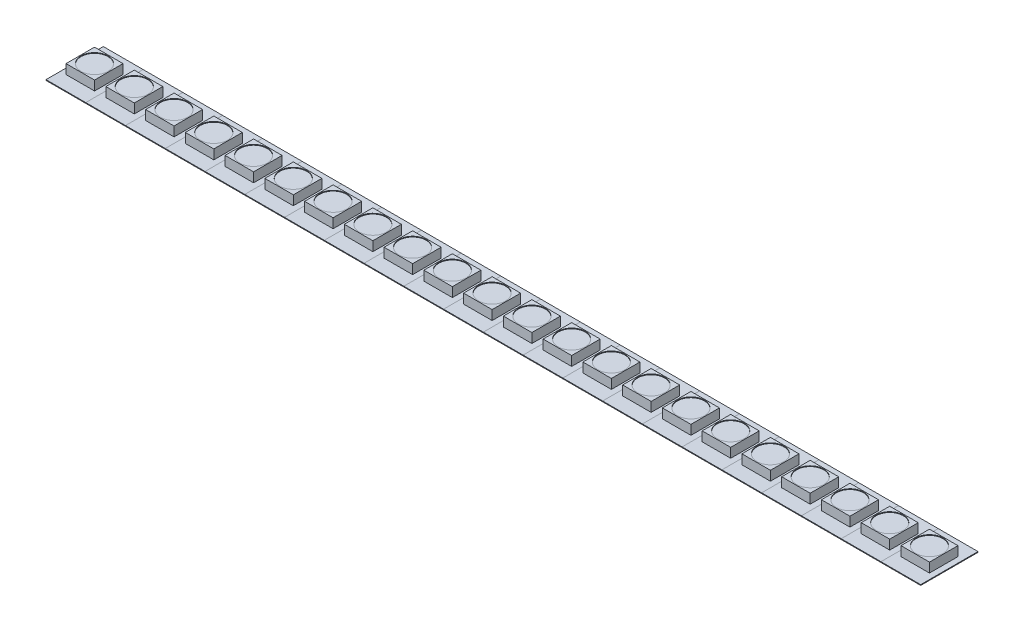
from build123d import *

# Parameters (mm, degrees)
SKETCH1_W           = 6.9088
SKETCH1_H           = 9.9568
BOSS_EXTRUDE1_DEPTH = 0.127
SKETCH3_W           = 4.953
SKETCH3_H           = 4.953
BOSS_EXTRUDE3_DEPTH = 1.651
SKETCH5_R           = 2.348345572
CUT_EXTRUDE1_DEPTH  = 0.127
LPATTERN1_COUNT     = 22
LPATTERN1_PITCH     = 6.9088


with BuildPart() as part:
    # Sketch1 → Boss-Extrude1 (new body)
    with BuildSketch(Plane(origin=(0, 0, 0), x_dir=(1, 0, 0), z_dir=(0, 1, 0))):
        Rectangle(SKETCH1_W, SKETCH1_H)
    extrude(amount=BOSS_EXTRUDE1_DEPTH)

    # Sketch3 → Boss-Extrude3 (add)
    with BuildSketch(Plane(origin=(0, 0.127, 0), x_dir=(1, 0, 0), z_dir=(0, 1, 0))):
        Rectangle(SKETCH3_W, SKETCH3_H)
    extrude(amount=BOSS_EXTRUDE3_DEPTH)

    # Sketch5 → Cut-Extrude1 (cut)
    with BuildSketch(Plane(origin=(0, 1.778, 0), x_dir=(1, 0, 0), z_dir=(0, 1, 0))):
        Circle(SKETCH5_R)
    extrude(amount=-CUT_EXTRUDE1_DEPTH, mode=Mode.SUBTRACT)


with BuildPart() as lpattern1_1:
    # LPattern1: pattern copy
    add(part.part.moved(Location(Vector(1, 0, 0) * (1 * LPATTERN1_PITCH))))


with BuildPart() as lpattern1_2:
    # LPattern1: pattern copy
    add(part.part.moved(Location(Vector(1, 0, 0) * (2 * LPATTERN1_PITCH))))


with BuildPart() as lpattern1_3:
    # LPattern1: pattern copy
    add(part.part.moved(Location(Vector(1, 0, 0) * (3 * LPATTERN1_PITCH))))


with BuildPart() as lpattern1_4:
    # LPattern1: pattern copy
    add(part.part.moved(Location(Vector(1, 0, 0) * (4 * LPATTERN1_PITCH))))


with BuildPart() as lpattern1_5:
    # LPattern1: pattern copy
    add(part.part.moved(Location(Vector(1, 0, 0) * (5 * LPATTERN1_PITCH))))


with BuildPart() as lpattern1_6:
    # LPattern1: pattern copy
    add(part.part.moved(Location(Vector(1, 0, 0) * (6 * LPATTERN1_PITCH))))


with BuildPart() as lpattern1_7:
    # LPattern1: pattern copy
    add(part.part.moved(Location(Vector(1, 0, 0) * (7 * LPATTERN1_PITCH))))


with BuildPart() as lpattern1_8:
    # LPattern1: pattern copy
    add(part.part.moved(Location(Vector(1, 0, 0) * (8 * LPATTERN1_PITCH))))


with BuildPart() as lpattern1_9:
    # LPattern1: pattern copy
    add(part.part.moved(Location(Vector(1, 0, 0) * (9 * LPATTERN1_PITCH))))


with BuildPart() as lpattern1_10:
    # LPattern1: pattern copy
    add(part.part.moved(Location(Vector(1, 0, 0) * (10 * LPATTERN1_PITCH))))


with BuildPart() as lpattern1_11:
    # LPattern1: pattern copy
    add(part.part.moved(Location(Vector(1, 0, 0) * (11 * LPATTERN1_PITCH))))


with BuildPart() as lpattern1_12:
    # LPattern1: pattern copy
    add(part.part.moved(Location(Vector(1, 0, 0) * (12 * LPATTERN1_PITCH))))


with BuildPart() as lpattern1_13:
    # LPattern1: pattern copy
    add(part.part.moved(Location(Vector(1, 0, 0) * (13 * LPATTERN1_PITCH))))


with BuildPart() as lpattern1_14:
    # LPattern1: pattern copy
    add(part.part.moved(Location(Vector(1, 0, 0) * (14 * LPATTERN1_PITCH))))


with BuildPart() as lpattern1_15:
    # LPattern1: pattern copy
    add(part.part.moved(Location(Vector(1, 0, 0) * (15 * LPATTERN1_PITCH))))


with BuildPart() as lpattern1_16:
    # LPattern1: pattern copy
    add(part.part.moved(Location(Vector(1, 0, 0) * (16 * LPATTERN1_PITCH))))


with BuildPart() as lpattern1_17:
    # LPattern1: pattern copy
    add(part.part.moved(Location(Vector(1, 0, 0) * (17 * LPATTERN1_PITCH))))


with BuildPart() as lpattern1_18:
    # LPattern1: pattern copy
    add(part.part.moved(Location(Vector(1, 0, 0) * (18 * LPATTERN1_PITCH))))


with BuildPart() as lpattern1_19:
    # LPattern1: pattern copy
    add(part.part.moved(Location(Vector(1, 0, 0) * (19 * LPATTERN1_PITCH))))


with BuildPart() as lpattern1_20:
    # LPattern1: pattern copy
    add(part.part.moved(Location(Vector(1, 0, 0) * (20 * LPATTERN1_PITCH))))


with BuildPart() as lpattern1_21:
    # LPattern1: pattern copy
    add(part.part.moved(Location(Vector(1, 0, 0) * (21 * LPATTERN1_PITCH))))


solid = Compound([part.part, lpattern1_1.part, lpattern1_2.part, lpattern1_3.part, lpattern1_4.part, lpattern1_5.part, lpattern1_6.part, lpattern1_7.part, lpattern1_8.part, lpattern1_9.part, lpattern1_10.part, lpattern1_11.part, lpattern1_12.part, lpattern1_13.part, lpattern1_14.part, lpattern1_15.part, lpattern1_16.part, lpattern1_17.part, lpattern1_18.part, lpattern1_19.part, lpattern1_20.part, lpattern1_21.part])
